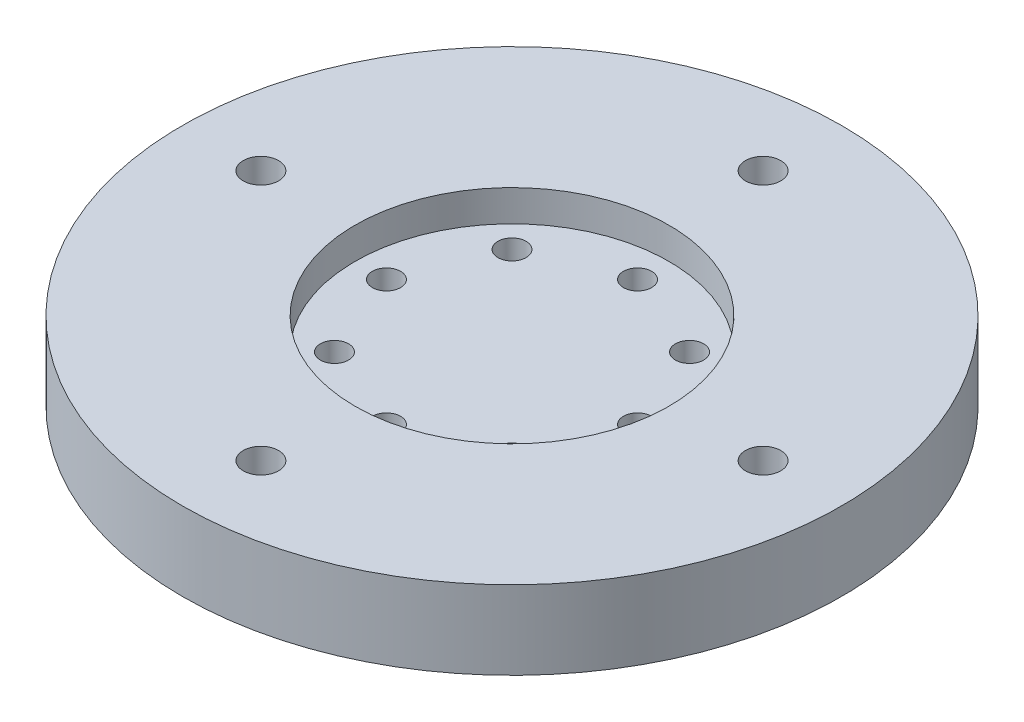
from build123d import *

# Parameters (mm, degrees)
SKETCH_1_R          = 21
EXTRUDE_1_DEPTH     = 5
SKETCH_2_R          = 10
CUT_EXTRUDE_1_DEPTH = 2
SKETCH_3_R          = 0.9
CUT_EXTRUDE_2_DEPTH = 3
SKETCH_4_R          = 1.125
CUT_EXTRUDE_3_DEPTH = 5


with BuildPart() as part:
    # 스케치1 → 보스-돌출1 (new body)
    with BuildSketch(Plane(origin=(0, 0, 0), x_dir=(1, 0, 0), z_dir=(0, 1, 0))):
        Circle(SKETCH_1_R)
    extrude(amount=EXTRUDE_1_DEPTH)

    # 스케치2 → 컷-돌출1 (cut)
    with BuildSketch(Plane(origin=(0, 5, 0), x_dir=(1, 0, 0), z_dir=(0, 1, 0))):
        Circle(SKETCH_2_R)
    extrude(amount=-CUT_EXTRUDE_1_DEPTH, mode=Mode.SUBTRACT)

    # 스케치3 → 컷-돌출2 (cut)
    with BuildSketch(Plane(origin=(0, 3, 0), x_dir=(1, 0, 0), z_dir=(0, 1, 0))):
        with Locations((5.656854249, 5.656854249)):
            Circle(SKETCH_3_R)
        with Locations((8, 0)):
            Circle(SKETCH_3_R)
        with Locations((0, 8)):
            Circle(SKETCH_3_R)
        with Locations((5.656854249, -5.656854249)):
            Circle(SKETCH_3_R)
        with Locations((0, -8)):
            Circle(SKETCH_3_R)
        with Locations((-5.656854249, -5.656854249)):
            Circle(SKETCH_3_R)
        with Locations((-8, 0)):
            Circle(SKETCH_3_R)
        with Locations((-5.656854249, 5.656854249)):
            Circle(SKETCH_3_R)
    extrude(amount=-CUT_EXTRUDE_2_DEPTH, mode=Mode.SUBTRACT)

    # 스케치4 → 컷-돌출3 (cut)
    with BuildSketch(Plane.XZ):
        with Locations((0, -16)):
            Circle(SKETCH_4_R)
        with Locations((-16, 0)):
            Circle(SKETCH_4_R)
        with Locations((0, 16)):
            Circle(SKETCH_4_R)
        with Locations((16, 0)):
            Circle(SKETCH_4_R)
    extrude(amount=-CUT_EXTRUDE_3_DEPTH, mode=Mode.SUBTRACT)


solid = part.part
